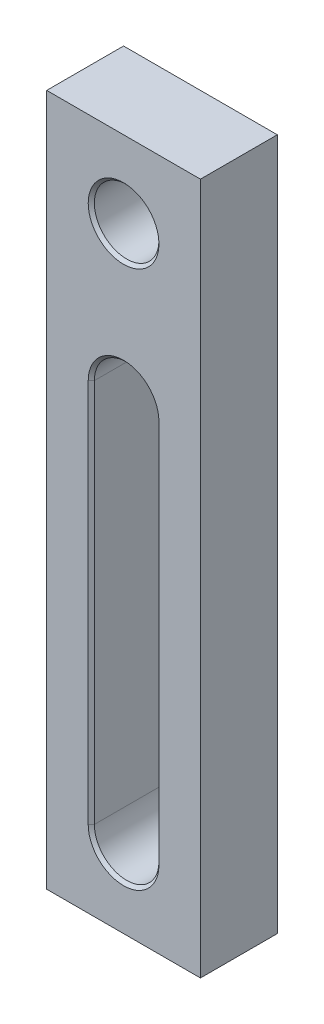
from build123d import *

# Parameters (mm, degrees)
SKETCH_1_W          = 50
SKETCH_1_H          = 225
EXTRUDE_1_DEPTH     = 25
SKETCH_2_R          = 10.5
CUT_EXTRUDE_1_DEPTH = 26
CHAMFER_1_SIZE      = 1


with BuildPart() as part:
    # Эскиз1 → Бобышка-Вытянуть1 (new body)
    with BuildSketch(Plane.XY):
        with Locations((25, 112.5)):
            Rectangle(SKETCH_1_W, SKETCH_1_H)
    extrude(amount=EXTRUDE_1_DEPTH)

    # Эскиз2 → Вырез-Вытянуть1 (cut, through all)
    with BuildSketch(Plane.XY.offset(25)):
        with Locations((25, 200)):
            Circle(SKETCH_2_R)
        with BuildLine():
            Line((14.5, 25), (14.5, 150))
            ThreePointArc((14.5, 150), (25, 160.5), (35.5, 150))
            Line((35.5, 150), (35.5, 25))
            ThreePointArc((35.5, 25), (25, 14.5), (14.5, 25))
        make_face()
    extrude(amount=-CUT_EXTRUDE_1_DEPTH, mode=Mode.SUBTRACT)

    # Фаска1
    chamfer_1_edges = [part.edges().sort_by_distance(p)[0] for p in [
        (25, 14.5, 0),
        (14.5, 87.5, 0),
        (25, 160.5, 0),
        (35.5, 87.5, 0),
        (25, 14.5, 25),
        (35.5, 87.5, 25),
        (25, 160.5, 25),
        (14.5, 87.5, 25),
        (14.5, 200, 0),
        (14.5, 200, 25),
    ]]
    chamfer(chamfer_1_edges, length=CHAMFER_1_SIZE)


solid = part.part
